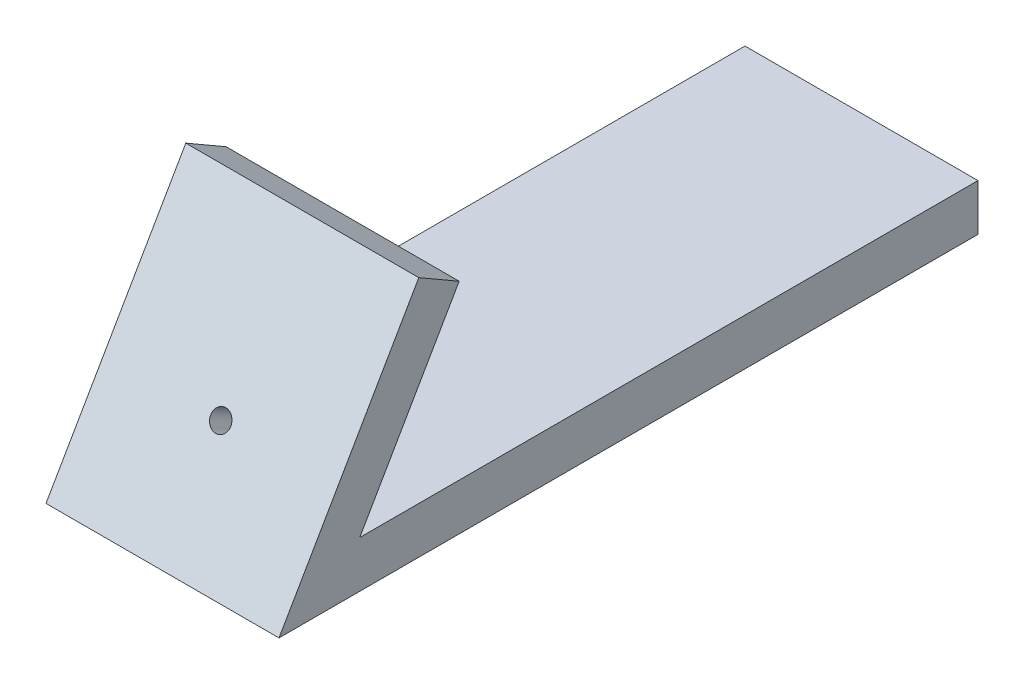
from build123d import *

# Parameters (mm, degrees)
EXTRUDE_1_DEPTH     = 50
SKETCH_2_R          = 2.15
CUT_EXTRUDE_1_DEPTH = 18


with BuildPart() as part:
    # 草图1 → 凸台-拉伸1 (new body)
    with BuildSketch(Plane(origin=(0, 0, 0), x_dir=(0, 0, -1), z_dir=(1, 0, 0))):
        Polygon((117.696324268, -1.952846431), (117.696324268, -11.952846431), (-32.303675732, -11.952846431), (-2.303675732, 40.008677796), (6.356578306, 35.008677796), (-14.983167656, -1.952846431), align=None)
    extrude(amount=EXTRUDE_1_DEPTH)

    # 草图2 → 切除-拉伸1 (cut)
    with BuildSketch(Plane(origin=(0, 10.999690302, 19.052022471), x_dir=(1, 0, 0), z_dir=(0, 0.5, 0.866025404))):
        with Locations((25, -1.503306522)):
            Circle(SKETCH_2_R)
    extrude(amount=-CUT_EXTRUDE_1_DEPTH, mode=Mode.SUBTRACT)


solid = part.part
